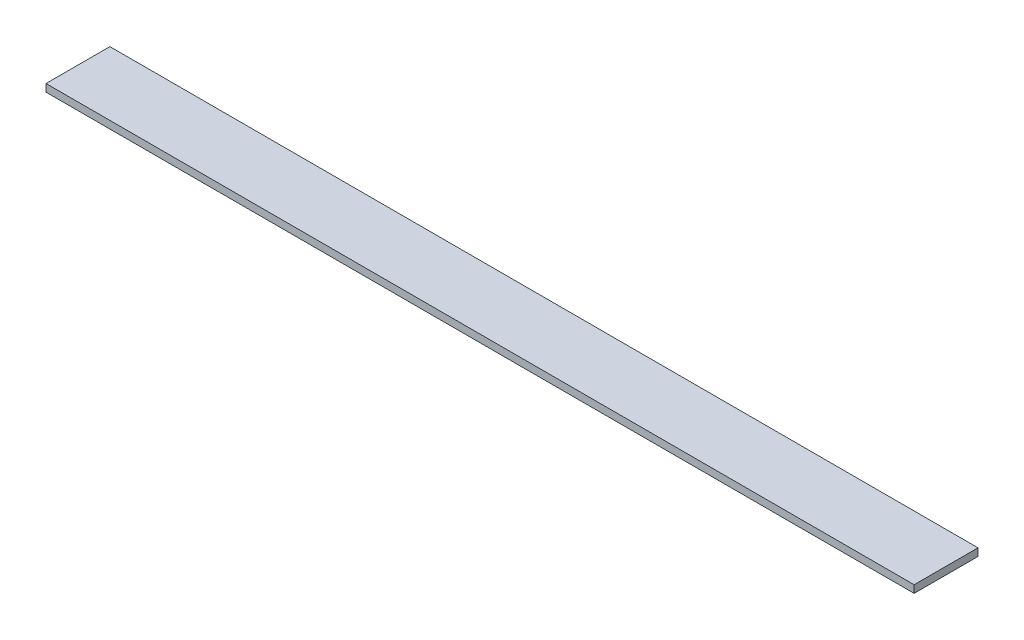
from build123d import *

# Parameters (mm, degrees)
SKETCH1_W           = 115.5
SKETCH1_H           = 8.5
BOSS_EXTRUDE1_DEPTH = 1


with BuildPart() as part:
    # Sketch1 → Boss-Extrude1 (new body)
    with BuildSketch(Plane(origin=(0, 0, 0), x_dir=(1, 0, 0), z_dir=(0, 1, 0))):
        with Locations((57.75, -4.25)):
            Rectangle(SKETCH1_W, SKETCH1_H)
    extrude(amount=-BOSS_EXTRUDE1_DEPTH)


solid = part.part
